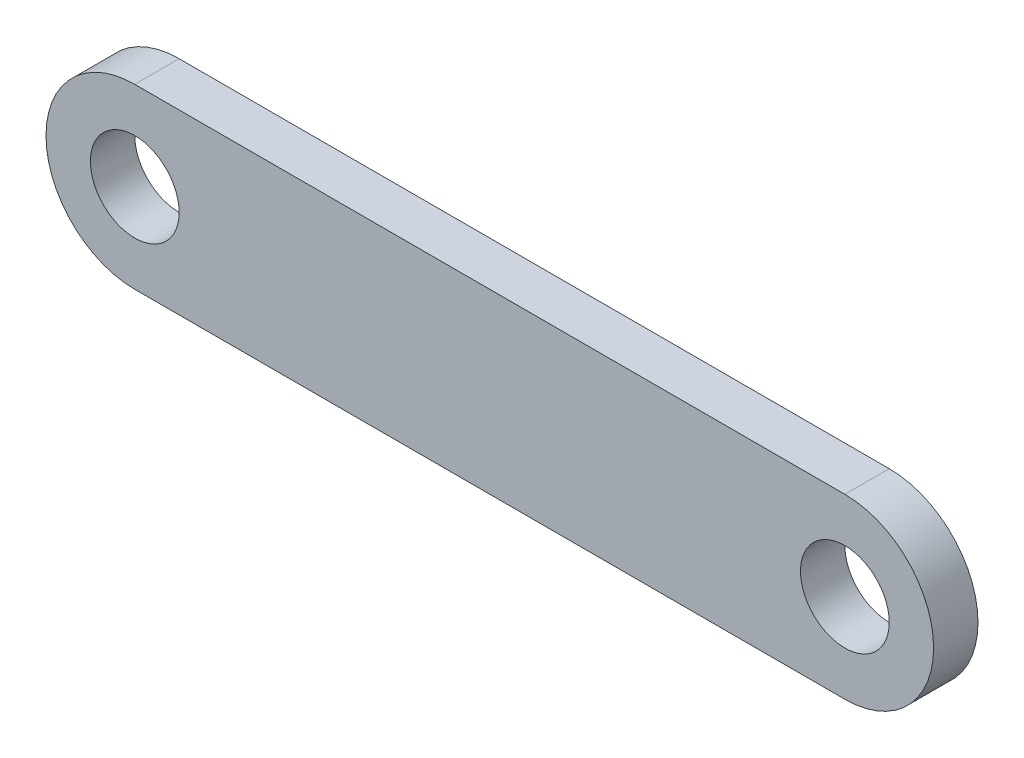
from build123d import *

# Parameters (mm, degrees)
SKETCH1_R           = 2
BOSS_EXTRUDE2_DEPTH = 1


with BuildPart() as part:
    # Sketch1 → Boss-Extrude2 (new body, symmetric)
    with BuildSketch(Plane.XY):
        with BuildLine():
            Line((-16, 4), (16, 4))
            ThreePointArc((16, 4), (20, 0), (16, -4))
            Line((16, -4), (-16, -4))
            ThreePointArc((-16, -4), (-20, 0), (-16, 4))
        make_face()
        with Locations((-16, 0)):
            Circle(SKETCH1_R, mode=Mode.SUBTRACT)
        with Locations((16, 0)):
            Circle(SKETCH1_R, mode=Mode.SUBTRACT)
    extrude(amount=BOSS_EXTRUDE2_DEPTH, both=True)


solid = part.part
